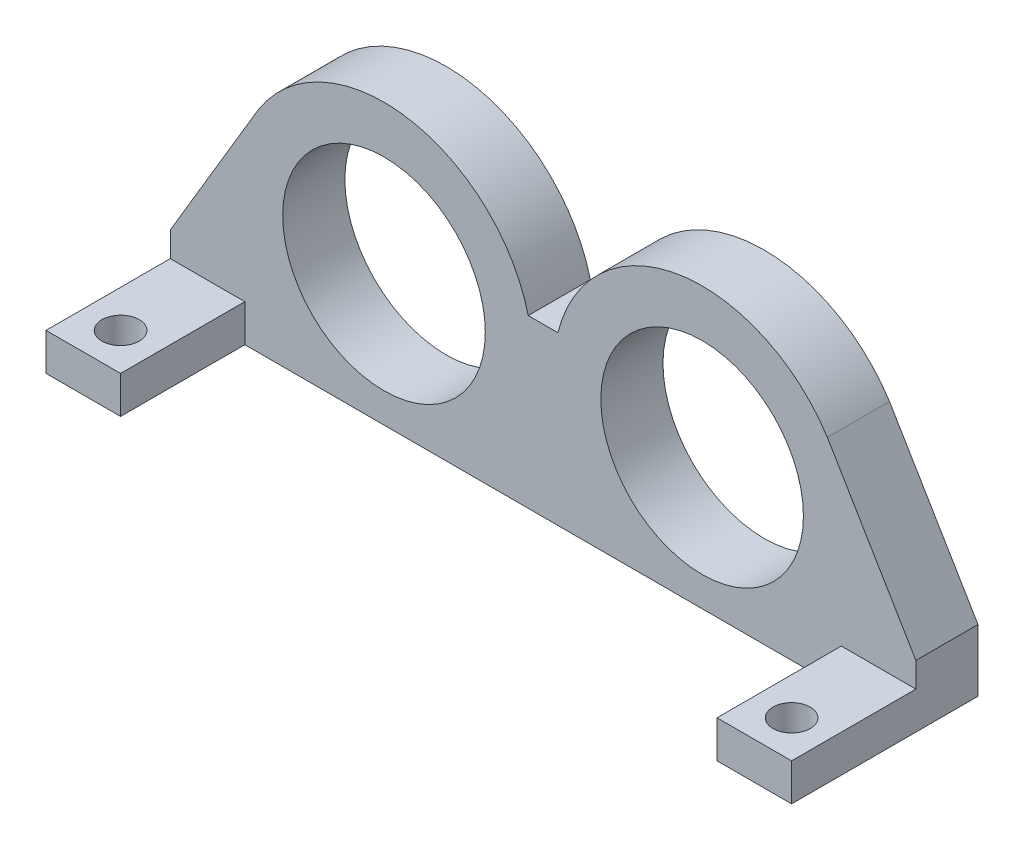
from build123d import *

# Parameters (mm, degrees)
SKETCH1_R           = 8.15
BOSS_EXTRUDE1_DEPTH = 5
SKETCH3_W           = 6
SKETCH3_H           = 3
BOSS_EXTRUDE2_DEPTH = 10
SKETCH4_R           = 1.5
CUT_EXTRUDE1_DEPTH  = 10


with BuildPart() as part:
    # Sketch1 → Boss-Extrude1 (new body)
    with BuildSketch(Plane.XY):
        with BuildLine():
            Line((30, 0), (-30, 0))
            Line((-30, 0), (-30, 5))
            Line((-30, 5), (-22.877190338, 16.984968219))
            ThreePointArc((-22.877190338, 16.984968219), (-10.866798453, 22.344543701), (-1.193346785, 13.433937918))
            Line((-1.193346785, 13.433937918), (1.193346785, 13.433937918))
            ThreePointArc((1.193346785, 13.433937918), (10.866798453, 22.344543701), (22.877190338, 16.984968219))
            Line((22.877190338, 16.984968219), (30, 5))
            Line((30, 5), (30, 0))
        make_face()
        with Locations((-12.8, 10.539733165)):
            Circle(SKETCH1_R, mode=Mode.SUBTRACT)
        with Locations((12.8, 10.539733165)):
            Circle(SKETCH1_R, mode=Mode.SUBTRACT)
    extrude(amount=BOSS_EXTRUDE1_DEPTH)

    # Sketch3 → Boss-Extrude2 (add)
    with BuildSketch(Plane.XY.offset(5)):
        with Locations((-27, 1.5)):
            Rectangle(SKETCH3_W, SKETCH3_H)
        with Locations((27, 1.5)):
            Rectangle(SKETCH3_W, SKETCH3_H)
    extrude(amount=BOSS_EXTRUDE2_DEPTH)

    # Sketch4 → Cut-Extrude1 (cut)
    with BuildSketch(Plane(origin=(0, 3, 0), x_dir=(1, 0, 0), z_dir=(0, 1, 0))):
        with Locations((-27, -12)):
            Circle(SKETCH4_R)
        with Locations((27, -12)):
            Circle(SKETCH4_R)
    extrude(amount=-CUT_EXTRUDE1_DEPTH, mode=Mode.SUBTRACT)


solid = part.part
